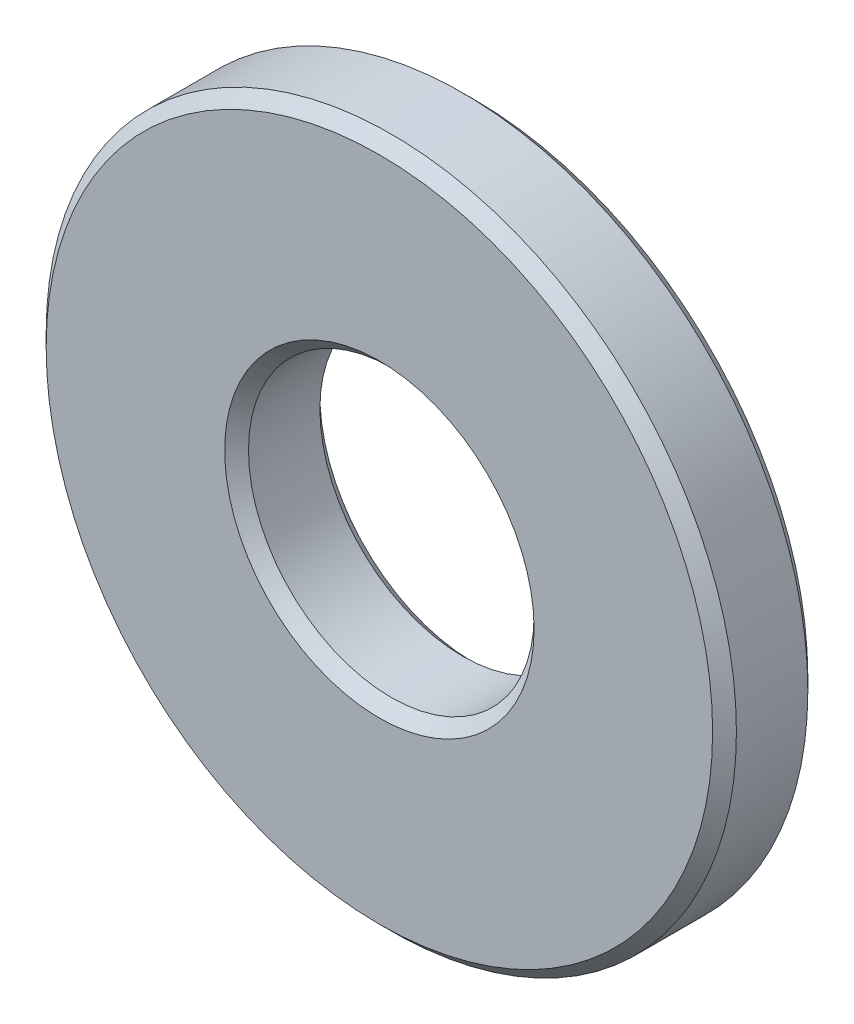
from build123d import *

# Parameters (mm, degrees)
SKETCH1_R           = 29
SKETCH1_R_2         = 12
BOSS_EXTRUDE1_DEPTH = 8
CHAMFER1_SIZE       = 1
CHAMFER2_SIZE       = 1


with BuildPart() as part:
    # Sketch1 → Boss-Extrude1 (new body)
    with BuildSketch(Plane.XY):
        Circle(SKETCH1_R)
        Circle(SKETCH1_R_2, mode=Mode.SUBTRACT)
    extrude(amount=BOSS_EXTRUDE1_DEPTH)

    # Chamfer1
    chamfer1_edges = [part.edges().sort_by_distance(p)[0] for p in [
        (-12, 0, 0),
        (-12, 0, 8),
    ]]
    chamfer(chamfer1_edges, length=CHAMFER1_SIZE)

    # Chamfer2
    chamfer2_edges = [part.edges().sort_by_distance(p)[0] for p in [
        (-29, 0, 0),
        (-29, 0, 8),
    ]]
    chamfer(chamfer2_edges, length=CHAMFER2_SIZE)


solid = part.part
